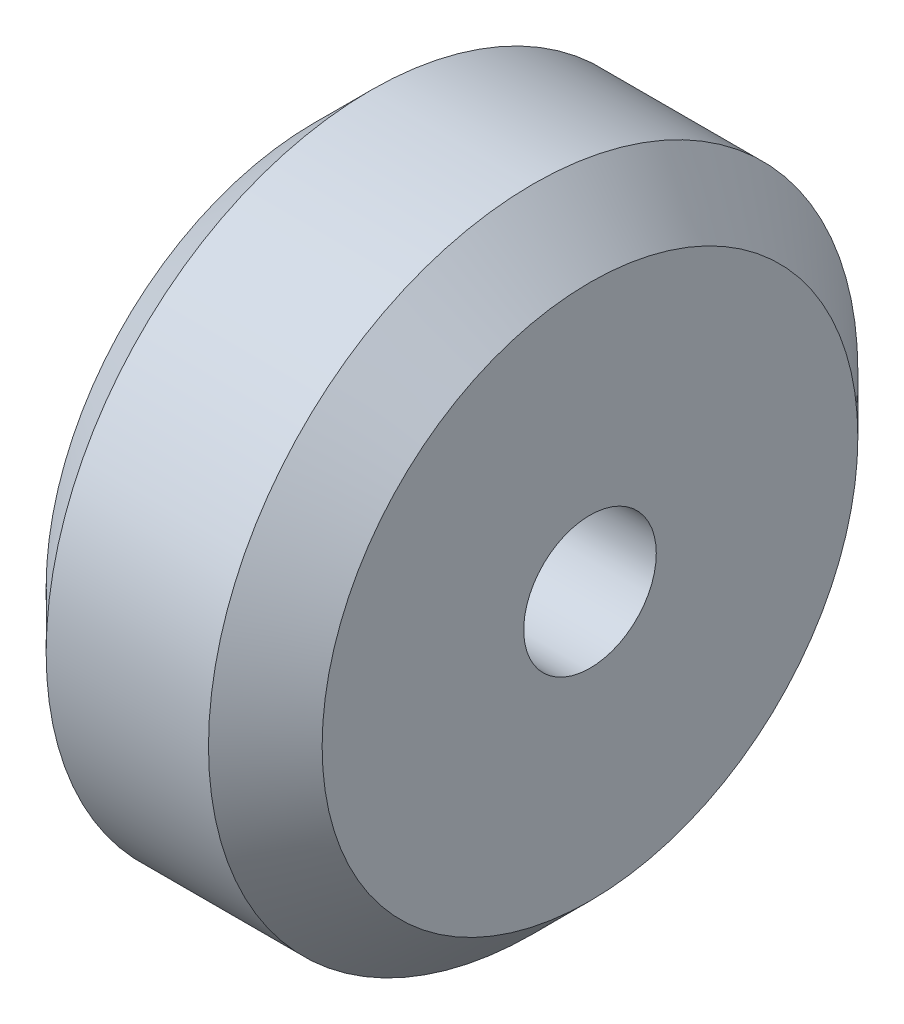
from build123d import *


with BuildPart() as part:
    # Croquis1 → Revolución1 (revolve)
    with BuildSketch(Plane.XY):
        Polygon((74.293469974, 89.042145638), (68.293469974, 89.042145638), (66.193469974, 86.942145638), (66.193469974, 79.492145638), (68.293469974, 79.492145638), (74.293469974, 79.492145638), (76.393469974, 79.492145638), (76.393469974, 86.942145638), align=None)
    revolve(axis=Axis((71.293469974, 77.042145638, 0), (-1, 0, 0)))


solid = part.part
